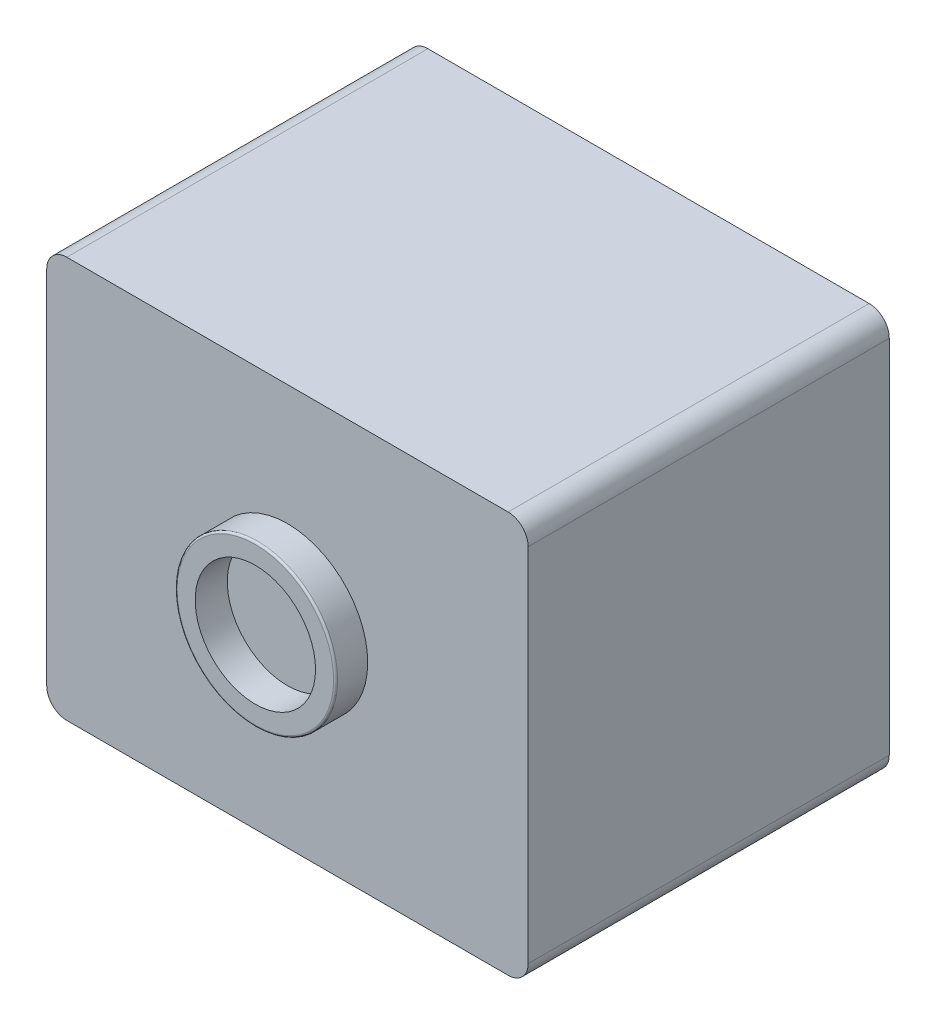
from build123d import *

# Parameters (mm, degrees)
SKETCH_1_W          = 12
SKETCH_1_H          = 10
EXTRUDE_1_DEPTH     = 9
FILLET_1_R          = 0.5
SKETCH_2_R          = 2
SKETCH_2_R_2        = 1.5
EXTRUDE_2_DEPTH     = 0.8
FILLET_2_R          = 0.05
SKETCH_7_R          = 2
CUT_EXTRUDE_4_DEPTH = 0.1


with BuildPart() as part:
    # 草图1 → 凸台-拉伸1 (new body)
    with BuildSketch(Plane.XY):
        Rectangle(SKETCH_1_W, SKETCH_1_H)
    extrude(amount=EXTRUDE_1_DEPTH)

    # 圆角1
    fillet_1_edges = [part.edges().sort_by_distance(p)[0] for p in [
        (6, -5, 4.5),
        (-6, -5, 4.5),
        (-6, 5, 4.5),
        (6, 5, 4.5),
    ]]
    fillet(fillet_1_edges, radius=FILLET_1_R)

    # 草图2 → 凸台-拉伸2 (add)
    with BuildSketch(Plane.XY.offset(9)):
        Circle(SKETCH_2_R)
        Circle(SKETCH_2_R_2, mode=Mode.SUBTRACT)
    extrude(amount=EXTRUDE_2_DEPTH)

    # 圆角2
    fillet_2_edges = [part.edges().sort_by_distance(p)[0] for p in [
        (-2, 0, 9.8),
    ]]
    fillet(fillet_2_edges, radius=FILLET_2_R)

    # 草图7 → 切除-拉伸4 (cut)
    with BuildSketch(Plane(origin=(0, 0, 0), x_dir=(-1, 0, 0), z_dir=(0, 0, -1))):
        Circle(SKETCH_7_R)
    extrude(amount=-CUT_EXTRUDE_4_DEPTH, mode=Mode.SUBTRACT)


solid = part.part
